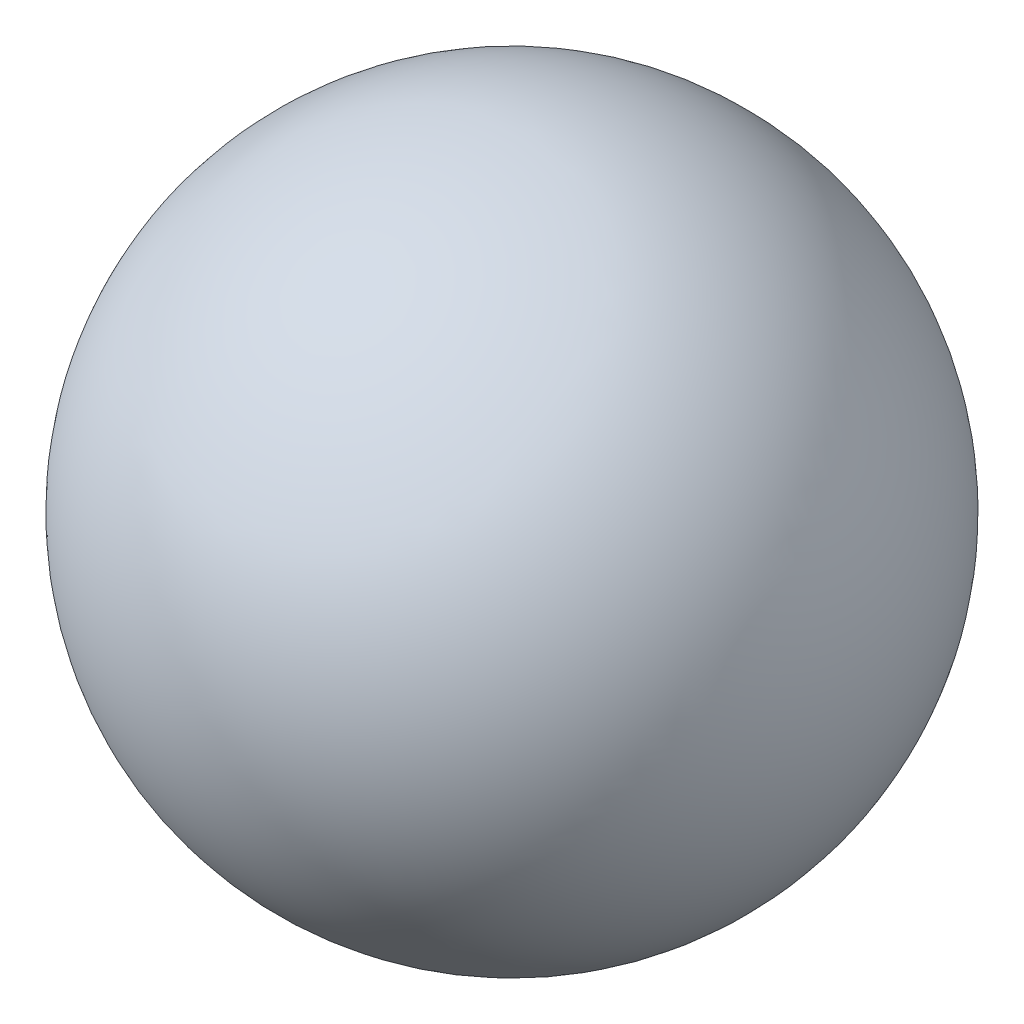
from build123d import *


with BuildPart() as part:
    # Sketch1 → Revolve1 (revolve)
    with BuildSketch(Plane.XY):
        with BuildLine():
            Line((0.8, 1), (0.2, 1))
            ThreePointArc((0.2, 1), (0.5, 1.3), (0.8, 1))
        make_face()
    revolve(axis=Axis((0.8, 1, 0), (-1, 0, 0)))


solid = part.part
